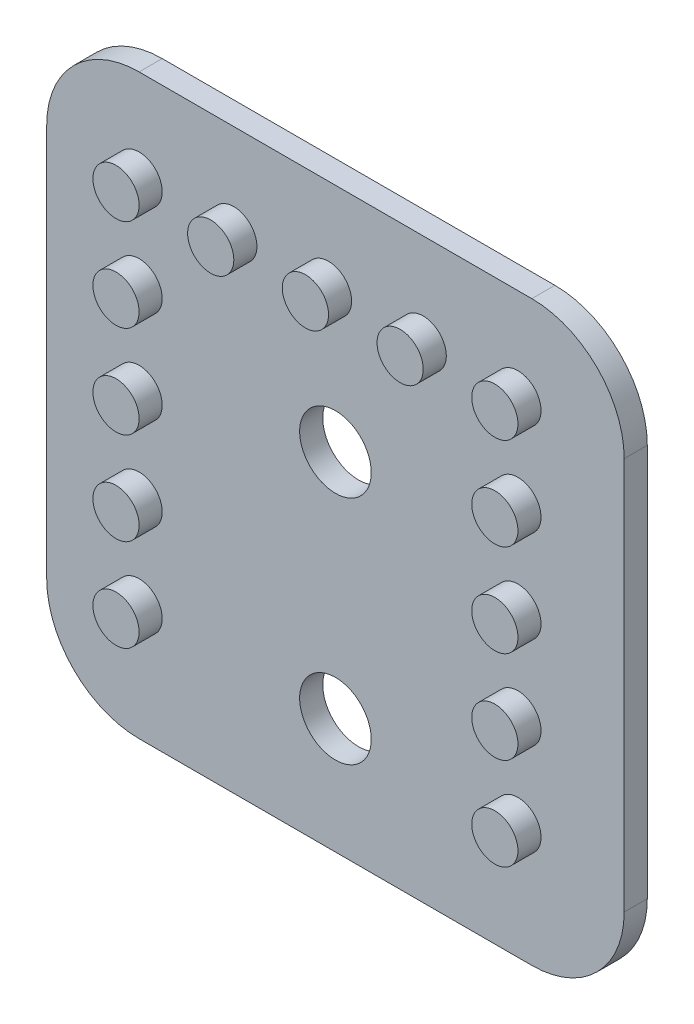
from build123d import *

# Parameters (mm, degrees)
SKETCH1_W           = 25
SKETCH1_H           = 25
BOSS_EXTRUDE1_DEPTH = 1
SKETCH2_R           = 1
BOSS_EXTRUDE2_DEPTH = 1
FILLET1_R           = 4
CUT_EXTRUDE1_REACH  = 3
SKETCH3_R           = 1.55


with BuildPart() as part:
    # Sketch1 → Boss-Extrude1 (new body)
    with BuildSketch(Plane.XY):
        with Locations((-23.5, 20.5)):
            Rectangle(SKETCH1_W, SKETCH1_H)
    extrude(amount=BOSS_EXTRUDE1_DEPTH)

    # Sketch2 → Boss-Extrude2 (add)
    with BuildSketch(Plane.XY.offset(1)):
        with Locations((-32, 29)):
            Circle(SKETCH2_R)
        with Locations((-27.9, 29)):
            Circle(SKETCH2_R)
        with Locations((-23.8, 29)):
            Circle(SKETCH2_R)
        with Locations((-19.7, 29)):
            Circle(SKETCH2_R)
        with Locations((-15.6, 29)):
            Circle(SKETCH2_R)
        with Locations((-32, 25)):
            Circle(SKETCH2_R)
        with Locations((-15.6, 25)):
            Circle(SKETCH2_R)
        with Locations((-32, 21)):
            Circle(SKETCH2_R)
        with Locations((-15.6, 21)):
            Circle(SKETCH2_R)
        with Locations((-32, 17)):
            Circle(SKETCH2_R)
        with Locations((-15.6, 17)):
            Circle(SKETCH2_R)
        with Locations((-32, 13)):
            Circle(SKETCH2_R)
        with Locations((-15.6, 13)):
            Circle(SKETCH2_R)
    extrude(amount=BOSS_EXTRUDE2_DEPTH)

    # Fillet1
    fillet1_edges = [part.edges().sort_by_distance(p)[0] for p in [
        (-11, 8, 0.5),
        (-36, 8, 0.5),
        (-36, 33, 0.5),
        (-11, 33, 0.5),
    ]]
    fillet(fillet1_edges, radius=FILLET1_R)

    # Sketch3 → Cut-Extrude1 (cut, up to next)
    with BuildSketch(Plane.XY.offset(1), mode=Mode.PRIVATE) as cut_extrude1_sk1:
        with Locations((-23.5, 23)):
            Circle(SKETCH3_R)
    cut_extrude1_tool1 = extrude(cut_extrude1_sk1.sketch, amount=-CUT_EXTRUDE1_REACH, mode=Mode.PRIVATE) & part.part
    add(cut_extrude1_tool1.solids().sort_by_distance((-23.5, 23, 1))[0], mode=Mode.SUBTRACT)
    # Sketch3 → Cut-Extrude1 (cut, up to next)
    with BuildSketch(Plane.XY.offset(1), mode=Mode.PRIVATE) as cut_extrude1_sk2:
        with Locations((-23.5, 13)):
            Circle(SKETCH3_R)
    cut_extrude1_tool2 = extrude(cut_extrude1_sk2.sketch, amount=-CUT_EXTRUDE1_REACH, mode=Mode.PRIVATE) & part.part
    add(cut_extrude1_tool2.solids().sort_by_distance((-23.5, 13, 1))[0], mode=Mode.SUBTRACT)


solid = part.part
